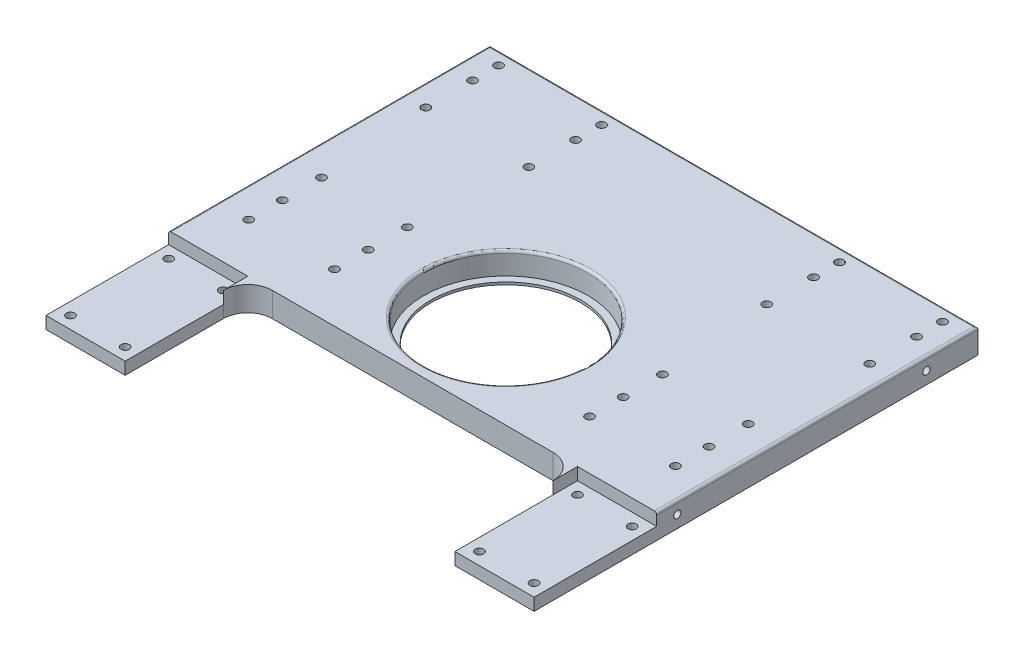
from build123d import *

# Parameters (mm, degrees)
SKIZZE1_W                        = 199
SKIZZE1_H                        = 420
AUFSATZ_LINEAR_AUSTRAGEN1_DEPTH  = 10
SKIZZE5_W                        = 199
SKIZZE5_H                        = 85
SCHNITT_LINEAR_AUSTRAGEN2_DEPTH  = 10
SKIZZE6_R                        = 1.7
SCHNITT_LINEAR_AUSTRAGEN3_DEPTH  = 11
SCHNITT_LINEAR_AUSTRAGEN4_DEPTH  = 4
SKIZZE16_W                       = 35
SKIZZE16_H                       = 7
SCHNITT_LINEAR_AUSTRAGEN10_DEPTH = 5
SCHNITT_LINEAR_AUSTRAGEN11_DEPTH = 35
SKIZZE20_R                       = 1.7
SCHNITT_LINEAR_AUSTRAGEN12_DEPTH = 11
SKIZZE21_W                       = 134.422077922
SKIZZE21_H                       = 50
SCHNITT_LINEAR_AUSTRAGEN13_DEPTH = 11
SCHNITT_LINEAR_AUSTRAGEN14_DEPTH = 11
AUFSATZ_LINEAR_AUSTRAGEN6_DEPTH  = 10
SKIZZE25_R                       = 1.7
SCHNITT_LINEAR_AUSTRAGEN15_DEPTH = 11
SCHNITT_LINEAR_AUSTRAGEN16_DEPTH = 200
SKIZZE27_R                       = 33.5
SCHNITT_LINEAR_AUSTRAGEN17_DEPTH = 11
SKIZZE28_R                       = 36.006256149
SKIZZE28_R_2                     = 30.5
AUFSATZ_LINEAR_AUSTRAGEN7_DEPTH  = 1
SKIZZE29_R                       = 1.5
SKIZZE29_R_2                     = 1.45
SCHNITT_LINEAR_AUSTRAGEN18_DEPTH = 10
SKIZZE30_R                       = 1.45
SCHNITT_LINEAR_AUSTRAGEN19_DEPTH = 10
SKIZZE31_R                       = 2.95
SCHNITT_LINEAR_AUSTRAGEN20_DEPTH = 3.5
VERRUNDUNG1_R                    = 10
AUFSATZ_LINEAR_AUSTRAGEN8_DEPTH  = 5
VERRUNDUNG2_R                    = 1
FASE1_SIZE                       = 0.62


with BuildPart() as part:
    # Skizze1 → Aufsatz-Linear austragen1 (new body)
    with BuildSketch(Plane(origin=(0, 0, 0), x_dir=(1, 0, 0), z_dir=(0, 1, 0))):
        Rectangle(SKIZZE1_W, SKIZZE1_H)
    extrude(amount=AUFSATZ_LINEAR_AUSTRAGEN1_DEPTH)

    # Skizze5 → Schnitt-Linear austragen2 (cut)
    with BuildSketch(Plane(origin=(0, 10, 0), x_dir=(1, 0, 0), z_dir=(0, 1, 0))):
        Polygon((99.5, -210), (18, -210), (99.5, -56), align=None)
        Polygon((-18, -210), (-99.5, -56), (-99.5, -210), align=None)
        with Locations((0, 167.5)):
            Rectangle(SKIZZE5_W, SKIZZE5_H)
        Polygon((67.211038961, -56), (-67.211038961, -56), (-2.646103896, -178), (2.646103896, -178), align=None)
    extrude(amount=-SCHNITT_LINEAR_AUSTRAGEN2_DEPTH, mode=Mode.SUBTRACT)

    # Skizze6 → Schnitt-Linear austragen3 (cut, through all)
    with BuildSketch(Plane(origin=(0, 10, 0), x_dir=(1, 0, 0), z_dir=(0, 1, 0))):
        with Locations((-11, -205)):
            Circle(SKIZZE6_R)
        with Locations((-11, -188.18)):
            Circle(SKIZZE6_R)
        with Locations((11, -205)):
            Circle(SKIZZE6_R)
        with Locations((11, -188.18)):
            Circle(SKIZZE6_R)
    extrude(amount=-SCHNITT_LINEAR_AUSTRAGEN3_DEPTH, mode=Mode.SUBTRACT)

    # Skizze7 → Schnitt-Linear austragen4 (cut)
    with BuildSketch(Plane.XZ):
        Polygon((-11, 208.406366588), (-8.05, 206.703183294), (-8.05, 203.296816706), (-11, 201.593633412), (-13.95, 203.296816706), (-13.95, 206.703183294), align=None)
        Polygon((11, 208.406366588), (8.05, 206.703183294), (8.05, 203.296816706), (11, 201.593633412), (13.95, 203.296816706), (13.95, 206.703183294), align=None)
        Polygon((-8.05, 186.476816706), (-8.05, 189.883183294), (-11, 191.586366588), (-13.95, 189.883183294), (-13.95, 186.476816706), (-11, 184.773633412), align=None)
        Polygon((8.05, 186.476816706), (8.05, 189.883183294), (11, 191.586366588), (13.95, 189.883183294), (13.95, 186.476816706), (11, 184.773633412), align=None)
    extrude(amount=-SCHNITT_LINEAR_AUSTRAGEN4_DEPTH, mode=Mode.SUBTRACT)

    # Skizze16 → Schnitt-Linear austragen10 (cut)
    with BuildSketch(Plane.XZ):
        with Locations((0, 196.59)):
            Rectangle(SKIZZE16_W, SKIZZE16_H)
    extrude(amount=-SCHNITT_LINEAR_AUSTRAGEN10_DEPTH, mode=Mode.SUBTRACT)

    # Skizze17 → Schnitt-Linear austragen11 (cut)
    with BuildSketch(Plane.ZY.offset(-17.5)):
        Polygon((193.09, 5), (196.59, 8.5), (200.09, 5), align=None)
    extrude(amount=SCHNITT_LINEAR_AUSTRAGEN11_DEPTH, mode=Mode.SUBTRACT)

    # Skizze20 → Schnitt-Linear austragen12 (cut, through all)
    with BuildSketch(Plane(origin=(0, 10, 0), x_dir=(1, 0, 0), z_dir=(0, 1, 0))):
        with Locations((90.5, 119.52)):
            Circle(SKIZZE20_R)
        with Locations((48.5, 119.52)):
            Circle(SKIZZE20_R)
        with Locations((-48.5, 119.52)):
            Circle(SKIZZE20_R)
        with Locations((-90.5, 119.52)):
            Circle(SKIZZE20_R)
        with Locations((87, 43.82)):
            Circle(SKIZZE20_R)
        with Locations((52, 43.82)):
            Circle(SKIZZE20_R)
        with Locations((-87, 43.82)):
            Circle(SKIZZE20_R)
        with Locations((-52, 43.82)):
            Circle(SKIZZE20_R)
        with Locations((90.5, 108.94)):
            Circle(SKIZZE20_R)
        with Locations((87, 27.84)):
            Circle(SKIZZE20_R)
        with Locations((48.5, 108.94)):
            Circle(SKIZZE20_R)
        with Locations((52, 27.84)):
            Circle(SKIZZE20_R)
        with Locations((-48.5, 108.94)):
            Circle(SKIZZE20_R)
        with Locations((-90.5, 108.94)):
            Circle(SKIZZE20_R)
        with Locations((-52, 27.84)):
            Circle(SKIZZE20_R)
        with Locations((-87, 27.84)):
            Circle(SKIZZE20_R)
        with Locations((90.5, 89.84)):
            Circle(SKIZZE20_R)
        with Locations((87, 14.13)):
            Circle(SKIZZE20_R)
        with Locations((52, 14.13)):
            Circle(SKIZZE20_R)
        with Locations((48.5, 89.84)):
            Circle(SKIZZE20_R)
        with Locations((-90.5, 89.84)):
            Circle(SKIZZE20_R)
        with Locations((-48.5, 89.84)):
            Circle(SKIZZE20_R)
        with Locations((-52, 14.13)):
            Circle(SKIZZE20_R)
        with Locations((-87, 14.13)):
            Circle(SKIZZE20_R)
    extrude(amount=-SCHNITT_LINEAR_AUSTRAGEN12_DEPTH, mode=Mode.SUBTRACT)

    # Skizze21 → Schnitt-Linear austragen13 (cut, through all)
    with BuildSketch(Plane(origin=(0, 10, 0), x_dir=(1, 0, 0), z_dir=(0, 1, 0))):
        with Locations((0, -31)):
            Rectangle(SKIZZE21_W, SKIZZE21_H)
    extrude(amount=-SCHNITT_LINEAR_AUSTRAGEN13_DEPTH, mode=Mode.SUBTRACT)

    # Skizze22 → Schnitt-Linear austragen14 (cut, through all)
    with BuildSketch(Plane(origin=(0, 10, 0), x_dir=(1, 0, 0), z_dir=(0, 1, 0))):
        with BuildLine():
            Line((-67.211038961, -56), (-2.646103896, -178))
            ThreePointArc((-2.646103896, -178), (-52.825886854, -126.471631215), (-67.211038961, -56))
        make_face()
    schnitt_linear_austragen14 = extrude(amount=-SCHNITT_LINEAR_AUSTRAGEN14_DEPTH, mode=Mode.SUBTRACT)

    # Skizze23 → Aufsatz-Linear austragen6 (add)
    with BuildSketch(Plane(origin=(0, 10, 0), x_dir=(1, 0, 0), z_dir=(0, 1, 0))):
        with BuildLine():
            Line((-99.5, -56), (-18, -210))
            ThreePointArc((-18, -210), (-75.095260266, -141.650251374), (-99.5, -56))
        make_face()
    aufsatz_linear_austragen6 = extrude(amount=-AUFSATZ_LINEAR_AUSTRAGEN6_DEPTH)

    # Spiegeln2: Schnitt-Linear austragen14, Aufsatz-Linear austragen6 across plane
    add(schnitt_linear_austragen14.mirror(Plane(origin=(0, 0, 0), x_dir=(0, 0, 1), z_dir=(1, 0, 0))), mode=Mode.SUBTRACT)
    add(aufsatz_linear_austragen6.mirror(Plane(origin=(0, 0, 0), x_dir=(0, 0, 1), z_dir=(1, 0, 0))))

    # Skizze25 → Schnitt-Linear austragen15 (cut, through all)
    with BuildSketch(Plane(origin=(0, 10, 0), x_dir=(1, 0, 0), z_dir=(0, 1, 0))):
        with Locations((-94.5, -11)):
            Circle(SKIZZE25_R)
        with Locations((-72.211038961, -11)):
            Circle(SKIZZE25_R)
        with Locations((-72.211038961, -51)):
            Circle(SKIZZE25_R)
        with Locations((-94.5, -51)):
            Circle(SKIZZE25_R)
    schnitt_linear_austragen15 = extrude(amount=-SCHNITT_LINEAR_AUSTRAGEN15_DEPTH, mode=Mode.SUBTRACT)

    # Spiegeln3: Schnitt-Linear austragen15 across plane
    add(schnitt_linear_austragen15.mirror(Plane(origin=(0, 0, 0), x_dir=(0, 0, 1), z_dir=(1, 0, 0))), mode=Mode.SUBTRACT)

    # Skizze26 → Schnitt-Linear austragen16 (cut, through all)
    with BuildSketch(Plane.ZY.offset(99.5)):
        Polygon((6, 5), (6, 13.101486595), (200.684563047, 82.546277137), (242.997216492, -41.037631402), (91.241487897, -60.284782055), (56, 0), (56, 5), align=None)
    extrude(amount=-SCHNITT_LINEAR_AUSTRAGEN16_DEPTH, mode=Mode.SUBTRACT)

    # Skizze27 → Schnitt-Linear austragen17 (cut, through all)
    with BuildSketch(Plane(origin=(0, 10, 0), x_dir=(1, 0, 0), z_dir=(0, 1, 0))):
        with Locations((0, 32)):
            Circle(SKIZZE27_R)
    extrude(amount=-SCHNITT_LINEAR_AUSTRAGEN17_DEPTH, mode=Mode.SUBTRACT)

    # Skizze28 → Aufsatz-Linear austragen7 (add)
    with BuildSketch(Plane.XZ):
        with Locations((0, -32)):
            Circle(SKIZZE28_R)
        with Locations((0, -32)):
            Circle(SKIZZE28_R_2, mode=Mode.SUBTRACT)
    extrude(amount=-AUFSATZ_LINEAR_AUSTRAGEN7_DEPTH)

    # Skizze29 → Schnitt-Linear austragen18 (cut)
    with BuildSketch(Plane.ZY.offset(99.5)):
        with Locations((-104, 5)):
            Circle(SKIZZE29_R)
        with Locations((-2.4, 5)):
            Circle(SKIZZE29_R_2)
    schnitt_linear_austragen18 = extrude(amount=-SCHNITT_LINEAR_AUSTRAGEN18_DEPTH, mode=Mode.SUBTRACT)

    # Skizze30 → Schnitt-Linear austragen19 (cut)
    with BuildSketch(Plane(origin=(0, 0, -125), x_dir=(-1, 0, 0), z_dir=(0, 0, -1))):
        with Locations((94.5, 5)):
            Circle(SKIZZE30_R)
        with Locations((78.5, 5)):
            Circle(SKIZZE30_R)
    schnitt_linear_austragen19 = extrude(amount=-SCHNITT_LINEAR_AUSTRAGEN19_DEPTH, mode=Mode.SUBTRACT)

    # Spiegeln4: Schnitt-Linear austragen18, Schnitt-Linear austragen19 across plane
    add(schnitt_linear_austragen18.mirror(Plane(origin=(0, 0, 0), x_dir=(0, 0, 1), z_dir=(1, 0, 0))), mode=Mode.SUBTRACT)
    add(schnitt_linear_austragen19.mirror(Plane(origin=(0, 0, 0), x_dir=(0, 0, 1), z_dir=(1, 0, 0))), mode=Mode.SUBTRACT)

    # Skizze31 → Schnitt-Linear austragen20 (cut)
    with BuildSketch(Plane.XZ):
        with Locations((-90.5, -119.52)):
            Circle(SKIZZE31_R)
        with Locations((-48.5, -119.52)):
            Circle(SKIZZE31_R)
        with Locations((-87, -43.82)):
            Circle(SKIZZE31_R)
        with Locations((-52, -43.82)):
            Circle(SKIZZE31_R)
        with Locations((52, -43.82)):
            Circle(SKIZZE31_R)
        with Locations((87, -43.82)):
            Circle(SKIZZE31_R)
        with Locations((48.5, -119.52)):
            Circle(SKIZZE31_R)
        with Locations((90.5, -119.52)):
            Circle(SKIZZE31_R)
        with Locations((-90.5, -108.94)):
            Circle(SKIZZE31_R)
        with Locations((-90.5, -89.84)):
            Circle(SKIZZE31_R)
        with Locations((-48.5, -89.84)):
            Circle(SKIZZE31_R)
        with Locations((-48.5, -108.94)):
            Circle(SKIZZE31_R)
        with Locations((-87, -14.13)):
            Circle(SKIZZE31_R)
        with Locations((-87, -27.84)):
            Circle(SKIZZE31_R)
        with Locations((-52, -27.84)):
            Circle(SKIZZE31_R)
        with Locations((-52, -14.13)):
            Circle(SKIZZE31_R)
        with Locations((48.5, -108.94)):
            Circle(SKIZZE31_R)
        with Locations((48.5, -89.84)):
            Circle(SKIZZE31_R)
        with Locations((90.5, -89.84)):
            Circle(SKIZZE31_R)
        with Locations((90.5, -108.94)):
            Circle(SKIZZE31_R)
        with Locations((52, -14.13)):
            Circle(SKIZZE31_R)
        with Locations((52, -27.84)):
            Circle(SKIZZE31_R)
        with Locations((87, -27.84)):
            Circle(SKIZZE31_R)
        with Locations((87, -14.13)):
            Circle(SKIZZE31_R)
    extrude(amount=-SCHNITT_LINEAR_AUSTRAGEN20_DEPTH, mode=Mode.SUBTRACT)

    # Verrundung1
    verrundung1_edges = [part.edges().sort_by_distance(p)[0] for p in [
        (-67.211038961, 2.5, 6),
        (67.211038961, 2.5, 6),
    ]]
    fillet(verrundung1_edges, radius=VERRUNDUNG1_R)

    # Skizze33 → Aufsatz-Linear austragen8 (add)
    with BuildSketch(Plane(origin=(0, 5, 0), x_dir=(1, 0, 0), z_dir=(0, 1, 0))):
        with BuildLine():
            Line((-67.211038961, -16), (-67.211038961, -6))
            Line((-67.211038961, -6), (-57.211038961, -6))
            ThreePointArc((-57.211038961, -6), (-64.282106773, -8.928932188), (-67.211038961, -16))
        make_face()
        with BuildLine():
            Line((67.211038961, -6), (57.211038961, -6))
            ThreePointArc((57.211038961, -6), (64.282106773, -8.928932188), (67.211038961, -16))
            Line((67.211038961, -16), (67.211038961, -6))
        make_face()
    extrude(amount=AUFSATZ_LINEAR_AUSTRAGEN8_DEPTH)

    # Verrundung2
    verrundung2_edges = [part.edges().sort_by_distance(p)[0] for p in [
        (-99.5, 10, -59.5),
        (99.5, 10, -59.5),
        (0, 10, -125),
        (-33.5, 10, -32),
    ]]
    fillet(verrundung2_edges, radius=VERRUNDUNG2_R)

    # Fase1
    fase1_edges = [part.edges().sort_by_distance(p)[0] for p in [
        (-93.45, 3.5, -119.52),
        (-92.2, 3.5, -119.52),
        (46.8, 3.5, -89.84),
        (45.55, 3.5, -89.84),
        (46.8, 3.5, -108.94),
        (45.55, 3.5, -108.94),
        (-54.95, 3.5, -14.13),
        (-53.7, 3.5, -14.13),
        (-54.95, 3.5, -27.84),
        (-53.7, 3.5, -27.84),
        (-89.95, 3.5, -27.84),
        (-88.7, 3.5, -27.84),
        (-89.95, 3.5, -14.13),
        (-88.7, 3.5, -14.13),
        (85.3, 3.5, -14.13),
        (84.05, 3.5, -14.13),
        (85.3, 3.5, -27.84),
        (84.05, 3.5, -27.84),
        (50.3, 3.5, -27.84),
        (49.05, 3.5, -27.84),
        (88.8, 3.5, -89.84),
        (87.55, 3.5, -89.84),
        (88.8, 3.5, -108.94),
        (87.55, 3.5, -108.94),
        (50.3, 3.5, -14.13),
        (49.05, 3.5, -14.13),
        (85.3, 3.5, -43.82),
        (84.05, 3.5, -43.82),
        (50.3, 3.5, -43.82),
        (49.05, 3.5, -43.82),
        (-54.95, 3.5, -43.82),
        (-53.7, 3.5, -43.82),
        (-89.95, 3.5, -43.82),
        (-88.7, 3.5, -43.82),
        (-51.45, 3.5, -119.52),
        (-51.45, 3.5, -108.94),
        (-50.2, 3.5, -108.94),
        (-51.45, 3.5, -89.84),
        (-50.2, 3.5, -89.84),
        (-93.45, 3.5, -89.84),
        (-92.2, 3.5, -89.84),
        (46.8, 3.5, -119.52),
        (45.55, 3.5, -119.52),
        (88.8, 3.5, -119.52),
        (87.55, 3.5, -119.52),
        (-93.45, 3.5, -108.94),
        (-92.2, 3.5, -108.94),
    ]]
    chamfer(fase1_edges, length=FASE1_SIZE)


solid = part.part
